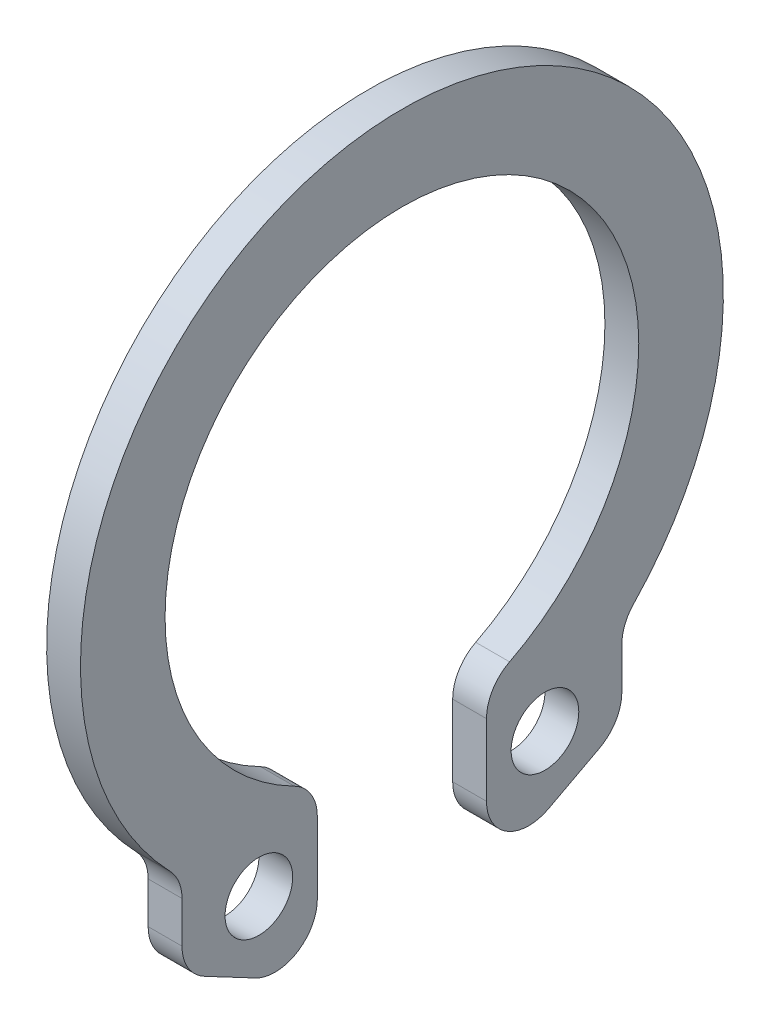
from build123d import *

# Parameters (mm, degrees)
SKETCH1_R           = 0.2
BOSS_EXTRUDE1_DEPTH = 0.2
FILLET1_R           = 0.25


with BuildPart() as part:
    # Sketch1 → Boss-Extrude1 (new body)
    with BuildSketch(Plane(origin=(0, 0, 0), x_dir=(0, 0, -1), z_dir=(1, 0, 0))):
        with BuildLine():
            Line((1.3, -1.385640646), (1.3, -1.884997731))
            Line((1.3, -1.884997731), (0.5, -2.307669683))
            Line((0.5, -2.307669683), (0.5, -1.307669683))
            ThreePointArc((0.5, -1.307669683), (0, 1.4), (-0.5, -1.307669683))
            Line((-0.5, -1.307669683), (-0.5, -2.307669683))
            Line((-0.5, -2.307669683), (-1.3, -1.884997731))
            Line((-1.3, -1.884997731), (-1.3, -1.385640646))
            ThreePointArc((-1.3, -1.385640646), (0, 1.9), (1.3, -1.385640646))
        make_face()
        with Locations((0.84550336, -1.706434434)):
            Circle(SKETCH1_R, mode=Mode.SUBTRACT)
        with Locations((-0.84550336, -1.706434434)):
            Circle(SKETCH1_R, mode=Mode.SUBTRACT)
    extrude(amount=BOSS_EXTRUDE1_DEPTH)

    # Fillet1
    fillet1_edges = [part.edges().sort_by_distance(p)[0] for p in [
        (0.1, -1.307669683, 0.5),
        (0.1, -2.307669683, 0.5),
        (0.1, -1.884997731, 1.3),
        (0.1, -1.385640646, 1.3),
        (0.1, -1.385640646, -1.3),
        (0.1, -1.884997731, -1.3),
        (0.1, -2.307669683, -0.5),
        (0.1, -1.307669683, -0.5),
    ]]
    fillet(fillet1_edges, radius=FILLET1_R)


solid = part.part
